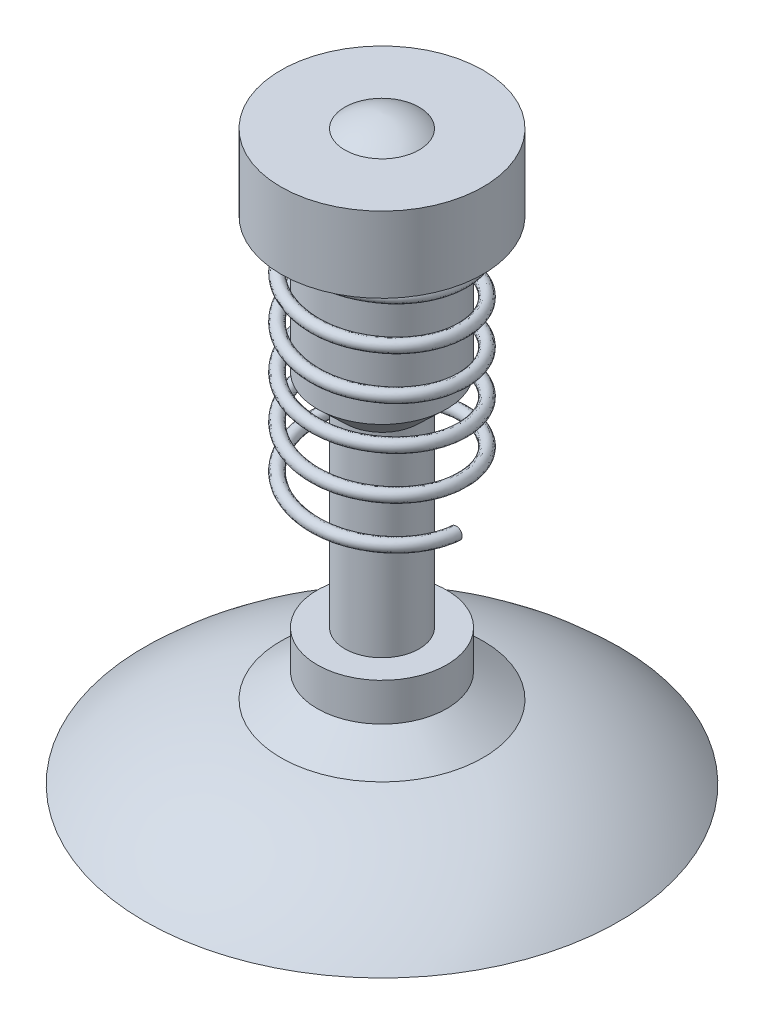
from build123d import *

# Parameters (mm, degrees)
SWEEP1_PITCH       = 0.2
SWEEP1_HEIGHT      = 1.1
SWEEP1_RADIUS      = 0.344
SWEEP1_START_ANGLE = -90
SKETCH3_R          = 0.0275


with BuildPart() as part:
    # Sketch1 → Revolve1 (revolve)
    with BuildSketch(Plane.XY):
        with BuildLine():
            Line((0, 2.69), (0, 0))
            Line((0, 0), (1.1, 0))
            ThreePointArc((1.1, 0), (0.80763957, 0.213447947), (0.468507193, 0.340033405))
            Line((0.468507193, 0.340033405), (0.3, 0.452743974))
            Line((0.3, 0.452743974), (0.3, 0.628538513))
            Line((0.3, 0.628538513), (0.172, 0.628538513))
            Line((0.172, 0.628538513), (0.172, 1.532886925))
            Line((0.172, 1.532886925), (0.3, 1.655))
            Line((0.3, 1.655), (0.3, 2.28))
            Line((0.3, 2.28), (0.468507193, 2.28))
            Line((0.468507193, 2.28), (0.468507193, 2.63))
            Line((0.468507193, 2.63), (0.172, 2.63))
            ThreePointArc((0.172, 2.63), (0.090362699, 2.672506403), (0, 2.69))
        make_face()
    revolve(axis=Axis((0, 2.69, 0), (0, -1, 0)))

    # Sweep1: sweep along a helix
    with BuildLine() as sweep1_path:
        add(Helix(SWEEP1_PITCH, SWEEP1_HEIGHT, SWEEP1_RADIUS, center=(0, 2.28, 0), direction=(0, -1, 0), lefthand=True, mode=Mode.PRIVATE).rotate(Axis((0, 2.28, 0), (0, -1, 0)), SWEEP1_START_ANGLE))
    # Sketch3 → Sweep1 (sweep)
    with BuildSketch(Plane.XY):
        with Locations((0.344, 2.18)):
            Circle(SKETCH3_R)
    sweep(path=sweep1_path.line, is_frenet=True)


solid = part.part
